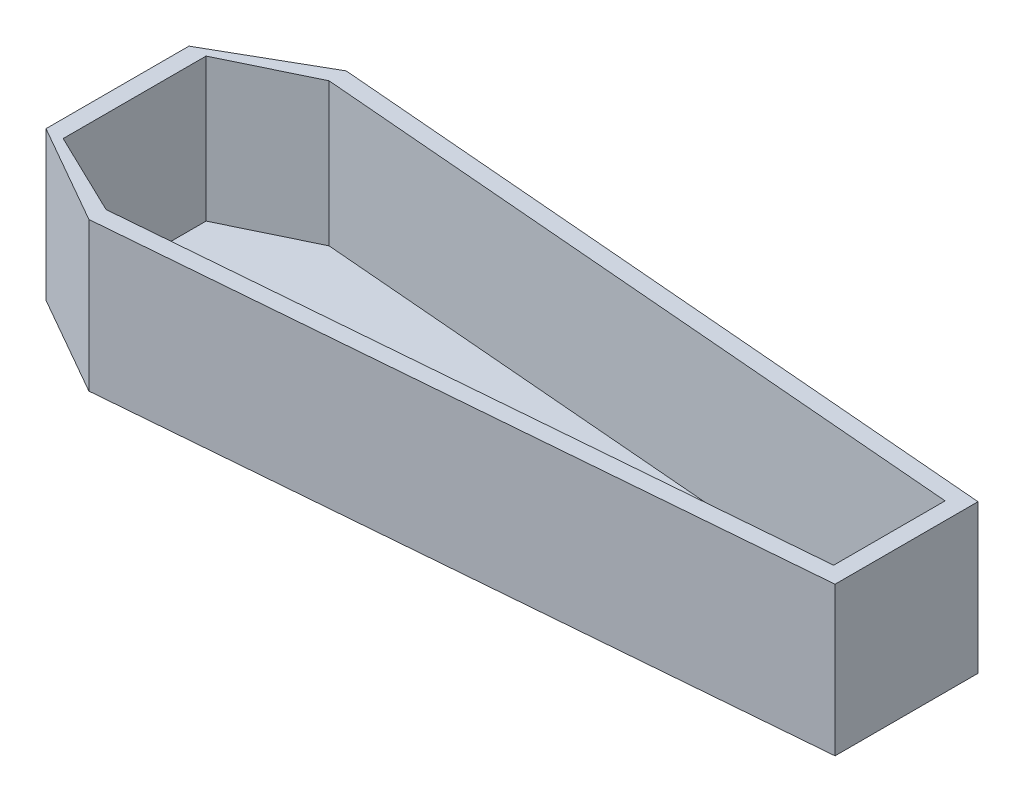
from build123d import *

# Parameters (mm, degrees)
BOSS_EXTRUDE5_DEPTH = 50
BOSS_EXTRUDE6_DEPTH = 2


with BuildPart() as part:
    # Sketch1 → Boss-Extrude5 (new body)
    with BuildSketch(Plane(origin=(0, 0, 0), x_dir=(1, 0, 0), z_dir=(0, 1, 0))):
        Polygon((-148.684110885, 49.061860601), (-183.684110885, 29.061860601), (-183.684110885, -20.938139399), (-148.684110885, -40.938139399), (92.307295507, -20.938139399), (92.307295507, -14.938139399), (92.307295507, 23.061860601), (92.307295507, 29.061860601), align=None)
        Polygon((-177.684110885, -20.938139399), (-177.684110885, 29.061860601), (-148.684110885, 43.061860601), (86.307295507, 23.559803668), (86.307295507, 23.061860601), (86.307295507, -14.938139399), (86.307295507, -15.436082465), (-148.684110885, -34.938139399), align=None, mode=Mode.SUBTRACT)
    extrude(amount=BOSS_EXTRUDE5_DEPTH)

    # Sketch3 → Boss-Extrude6 (add)
    with BuildSketch(Plane.XZ):
        Polygon((-183.684110885, 20.938139399), (-183.684110885, -29.061860601), (-148.684110885, -49.061860601), (92.307295507, -29.061860601), (92.307295507, 20.938139399), (-148.684110885, 40.938139399), align=None)
    extrude(amount=BOSS_EXTRUDE6_DEPTH)


solid = part.part
